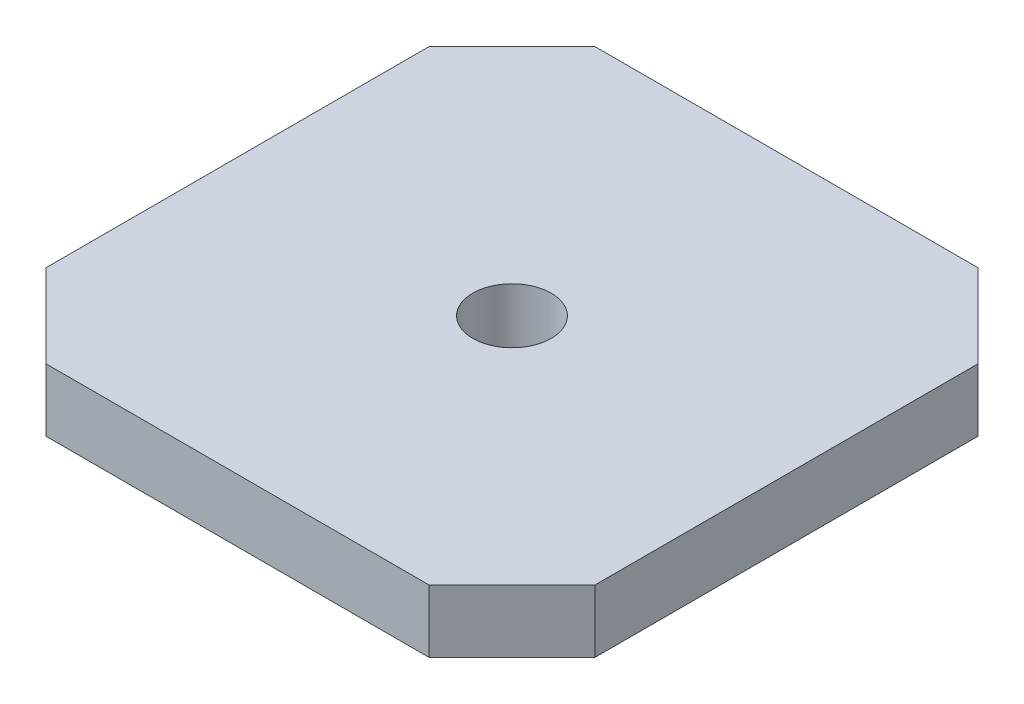
from build123d import *

# Parameters (mm, degrees)
CROQUIS1_W              = 35
CROQUIS1_H              = 35
SALIENTE_EXTRUIR1_DEPTH = 4
CROQUIS2_OUTSIDE_W      = 46.932
CROQUIS2_OUTSIDE_H      = 46.932
CORTAR_EXTRUIR2_DEPTH   = 18
CROQUIS3_R              = 2.5
CORTAR_EXTRUIR3_DEPTH   = 5


with BuildPart() as part:
    # Croquis1 → Saliente-Extruir1 (new body)
    with BuildSketch(Plane(origin=(0, 0, 0), x_dir=(1, 0, 0), z_dir=(0, 1, 0))):
        with Locations((17.5, 17.5)):
            Rectangle(CROQUIS1_W, CROQUIS1_H)
    extrude(amount=SALIENTE_EXTRUIR1_DEPTH)

    # Croquis2 outside → Cortar-Extruir2 (cut)
    with BuildSketch(Plane(origin=(0, 4, 0), x_dir=(1, 0, 0), z_dir=(0, 1, 0))):
        with Locations((17.5, 17.5)):
            Rectangle(CROQUIS2_OUTSIDE_W, CROQUIS2_OUTSIDE_H)
        Polygon((5.30151519, 35), (0, 29.69848481), (0, 5.30151519), (5.30151519, 0), (29.69848481, 0), (35, 5.30151519), (35, 29.69848481), (29.69848481, 35), align=None, mode=Mode.SUBTRACT)
    extrude(amount=-CORTAR_EXTRUIR2_DEPTH, mode=Mode.SUBTRACT)

    # Croquis3 → Cortar-Extruir3 (cut, through all)
    with BuildSketch(Plane(origin=(0, 4, 0), x_dir=(1, 0, 0), z_dir=(0, 1, 0))):
        with Locations((17.5, 17.5)):
            Circle(CROQUIS3_R)
    extrude(amount=-CORTAR_EXTRUIR3_DEPTH, mode=Mode.SUBTRACT)


solid = part.part
